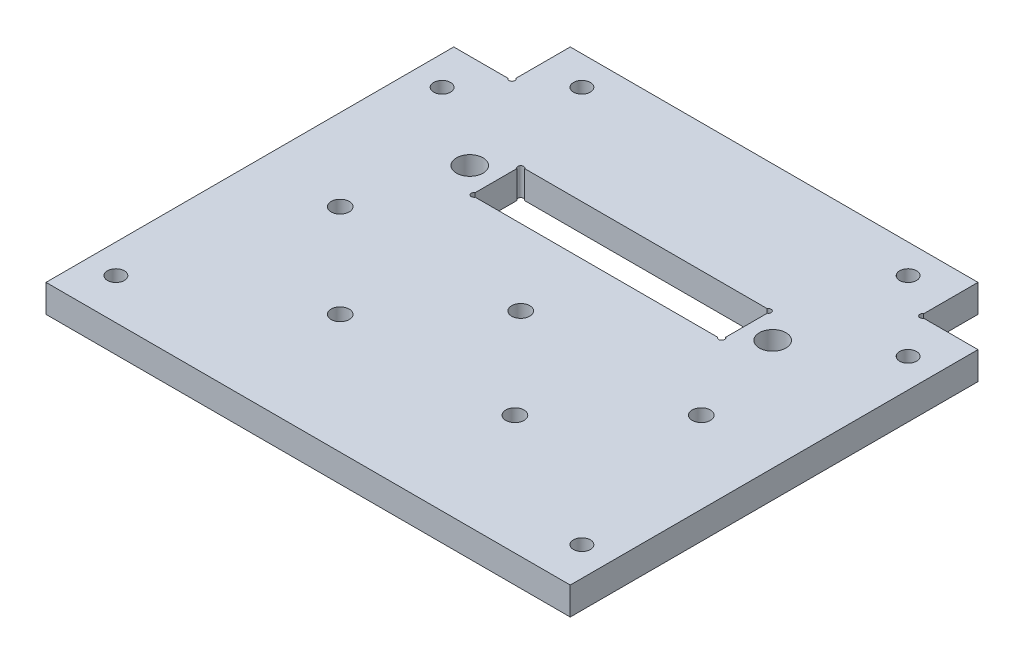
from build123d import *

# Parameters (mm, degrees)
BASE_DEPTH         = 4.7625
SKETCH2_R          = 1.5625
CUT_EXTRUDE1_DEPTH = 5.7625
SKETCH3_R          = 2.286
SKETCH3_W          = 43
SKETCH3_H          = 8.5
CUT_EXTRUDE2_DEPTH = 5.7625
SKETCH4_R          = 1.45
CUT_EXTRUDE3_DEPTH = 5.7625
SKETCH5_R          = 0.5
CUT_EXTRUDE4_DEPTH = 5.7625


with BuildPart() as part:
    # Sketch1 → Base (new body)
    with BuildSketch(Plane(origin=(0, 0, 0), x_dir=(1, 0, 0), z_dir=(0, 1, 0))):
        Polygon((-35, 0), (-45, 0), (-45, -70), (45, -70), (45, 0), (35, 0), (35, 10), (-35, 10), align=None)
    extrude(amount=BASE_DEPTH)

    # Sketch2 → Cut-Extrude1 (cut, through all)
    with BuildSketch(Plane(origin=(0, 4.7625, 0), x_dir=(1, 0, 0), z_dir=(0, 1, 0))):
        with Locations((-31, -33.5)):
            Circle(SKETCH2_R)
        with Locations((0, -33.5)):
            Circle(SKETCH2_R)
        with Locations((31, -33.5)):
            Circle(SKETCH2_R)
        with Locations((15, -49.5)):
            Circle(SKETCH2_R)
        with Locations((-15, -49.5)):
            Circle(SKETCH2_R)
    extrude(amount=-CUT_EXTRUDE1_DEPTH, mode=Mode.SUBTRACT)

    # Sketch3 → Cut-Extrude2 (cut, through all)
    with BuildSketch(Plane(origin=(0, 4.7625, 0), x_dir=(1, 0, 0), z_dir=(0, 1, 0))):
        with Locations((-26, -16.25)):
            Circle(SKETCH3_R)
        with Locations((26, -16.25)):
            Circle(SKETCH3_R)
        with Locations((0, -16.25)):
            Rectangle(SKETCH3_W, SKETCH3_H)
    extrude(amount=-CUT_EXTRUDE2_DEPTH, mode=Mode.SUBTRACT)

    # Sketch4 → Cut-Extrude3 (cut, through all)
    with BuildSketch(Plane(origin=(0, 4.7625, 0), x_dir=(1, 0, 0), z_dir=(0, 1, 0))):
        with Locations((-28, 5)):
            Circle(SKETCH4_R)
        with Locations((-40, -7)):
            Circle(SKETCH4_R)
        with Locations((-40, -63)):
            Circle(SKETCH4_R)
        with Locations((40, -63)):
            Circle(SKETCH4_R)
        with Locations((40, -7)):
            Circle(SKETCH4_R)
        with Locations((28, 5)):
            Circle(SKETCH4_R)
    extrude(amount=-CUT_EXTRUDE3_DEPTH, mode=Mode.SUBTRACT)

    # Sketch5 → Cut-Extrude4 (cut, through all)
    with BuildSketch(Plane(origin=(0, 4.7625, 0), x_dir=(1, 0, 0), z_dir=(0, 1, 0))):
        with Locations((-35.25, 0.25)):
            Circle(SKETCH5_R)
        with Locations((-21.25, -12.25)):
            Circle(SKETCH5_R)
        with Locations((-21.25, -20.25)):
            Circle(SKETCH5_R)
        with Locations((35.25, 0.25)):
            Circle(SKETCH5_R)
        with Locations((21.25, -12.25)):
            Circle(SKETCH5_R)
        with Locations((21.25, -20.25)):
            Circle(SKETCH5_R)
    extrude(amount=-CUT_EXTRUDE4_DEPTH, mode=Mode.SUBTRACT)


solid = part.part
